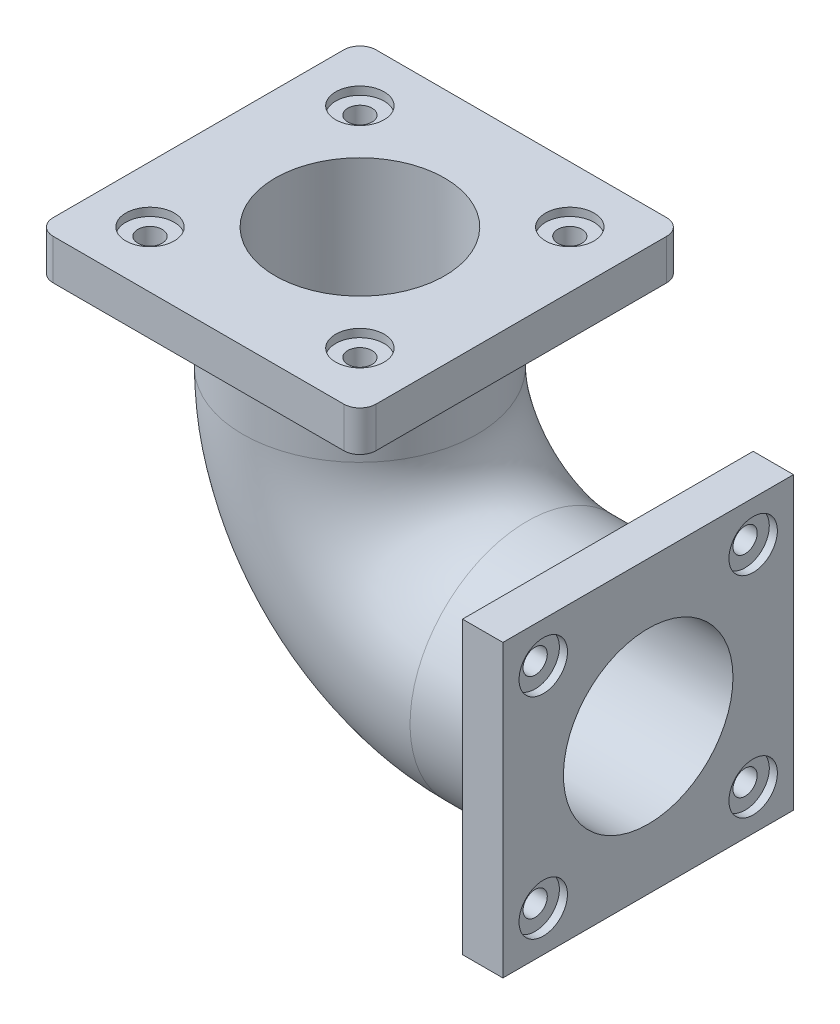
from build123d import *

# Parameters (mm, degrees)
SKETCH2_R           = 145
SKETCH2_R_2         = 105
SKETCH5_W           = 360
SKETCH5_H           = 360
SKETCH5_R           = 145
BOSS_EXTRUDE2_DEPTH = 50
SKETCH6_R           = 145
BOSS_EXTRUDE4_DEPTH = 50
SKETCH12_R          = 30
CUT_EXTRUDE2_DEPTH  = 10
SKETCH13_R          = 15
CUT_EXTRUDE4_DEPTH  = 40
CIRPATTERN3_COUNT   = 4
SKETCH14_R          = 30
CUT_EXTRUDE5_DEPTH  = 10
CUT_EXTRUDE6_START  = -50
SKETCH15_R          = 15
CUT_EXTRUDE6_DEPTH  = 40
CIRPATTERN4_COUNT   = 4


with BuildPart() as part:
    # Sweep-Thin2: sweep along a path in Sketch1
    with BuildLine(Plane.XY) as sweep_thin2_path:
        Line((0, 0), (-150, 0))
        ThreePointArc((-150, 0), (-296.448608391, 60.660999786), (-357.109608177, 207.109608177))
        Line((-357.109608177, 207.109608177), (-357.109608177, 357.109608177))
    # Sketch2 → Sweep-Thin2 (sweep)
    with BuildSketch(Plane(origin=(0, 0, 0), x_dir=(0, 0, -1), z_dir=(1, 0, 0))):
        Circle(SKETCH2_R)
        Circle(SKETCH2_R_2, mode=Mode.SUBTRACT)
    sweep(path=sweep_thin2_path.line)

    # Sketch5 → Boss-Extrude2 (add)
    with BuildSketch(Plane(origin=(0, 0, 0), x_dir=(0, 0, -1), z_dir=(1, 0, 0))):
        Rectangle(SKETCH5_W, SKETCH5_H)
        Circle(SKETCH5_R, mode=Mode.SUBTRACT)
    extrude(amount=-BOSS_EXTRUDE2_DEPTH)

    # Sketch6 → Boss-Extrude4 (add)
    with BuildSketch(Plane(origin=(0, 357.109608177, 0), x_dir=(1, 0, 0), z_dir=(0, 1, 0))):
        with BuildLine():
            Line((-537.109608177, 200), (-177.109608177, 200))
            ThreePointArc((-177.109608177, 200), (-162.967472553, 194.142135624), (-157.109608177, 180))
            Line((-157.109608177, 180), (-157.109608177, -180))
            ThreePointArc((-157.109608177, -180), (-162.967472553, -194.142135624), (-177.109608177, -200))
            Line((-177.109608177, -200), (-537.109608177, -200))
            ThreePointArc((-537.109608177, -200), (-551.2517438, -194.142135624), (-557.109608177, -180))
            Line((-557.109608177, -180), (-557.109608177, 180))
            ThreePointArc((-557.109608177, 180), (-551.2517438, 194.142135624), (-537.109608177, 200))
        make_face()
        with Locations((-357.109608177, 0)):
            Circle(SKETCH6_R, mode=Mode.SUBTRACT)
    extrude(amount=-BOSS_EXTRUDE4_DEPTH)

    # Sketch12 → Cut-Extrude2 (cut)
    with BuildSketch(Plane(origin=(0, 357.109608177, 0), x_dir=(1, 0, 0), z_dir=(0, 1, 0))):
        with Locations((-487.109608177, 130)):
            Circle(SKETCH12_R)
    cut_extrude2 = extrude(amount=-CUT_EXTRUDE2_DEPTH, mode=Mode.SUBTRACT)

    # Sketch13 → Cut-Extrude4 (cut)
    with BuildSketch(Plane(origin=(0, 347.109608177, 0), x_dir=(1, 0, 0), z_dir=(0, 1, 0))):
        with Locations((-487.109608177, 130)):
            Circle(SKETCH13_R)
    cut_extrude4 = extrude(amount=-CUT_EXTRUDE4_DEPTH, mode=Mode.SUBTRACT)

    # CirPattern3: Cut-Extrude2, Cut-Extrude4 ×4 about axis
    cirpattern3_axis = Axis((-357.109608177, 0, 0), (0, 1, 0))
    for i in range(1, CIRPATTERN3_COUNT):
        add(cut_extrude2.rotate(cirpattern3_axis, i * 360 / CIRPATTERN3_COUNT), mode=Mode.SUBTRACT)
        add(cut_extrude4.rotate(cirpattern3_axis, i * 360 / CIRPATTERN3_COUNT), mode=Mode.SUBTRACT)

    # Sketch14 → Cut-Extrude5 (cut)
    with BuildSketch(Plane(origin=(0, 0, 0), x_dir=(0, 0, -1), z_dir=(1, 0, 0))):
        with Locations((-130, 130)):
            Circle(SKETCH14_R)
    cut_extrude5 = extrude(amount=-CUT_EXTRUDE5_DEPTH, mode=Mode.SUBTRACT)

    # Sketch15 → Cut-Extrude6 (cut)
    with BuildSketch(Plane(origin=(0, 0, 0), x_dir=(0, 0, -1), z_dir=(1, 0, 0)).offset(CUT_EXTRUDE6_START)):
        with Locations((-130, 130)):
            Circle(SKETCH15_R)
    cut_extrude6 = extrude(amount=CUT_EXTRUDE6_DEPTH, mode=Mode.SUBTRACT)

    # CirPattern4: Cut-Extrude5, Cut-Extrude6 ×4 about axis
    cirpattern4_axis = Axis((0, 0, 0), (1, 0, 0))
    for i in range(1, CIRPATTERN4_COUNT):
        add(cut_extrude5.rotate(cirpattern4_axis, i * 360 / CIRPATTERN4_COUNT), mode=Mode.SUBTRACT)
        add(cut_extrude6.rotate(cirpattern4_axis, i * 360 / CIRPATTERN4_COUNT), mode=Mode.SUBTRACT)


solid = part.part
